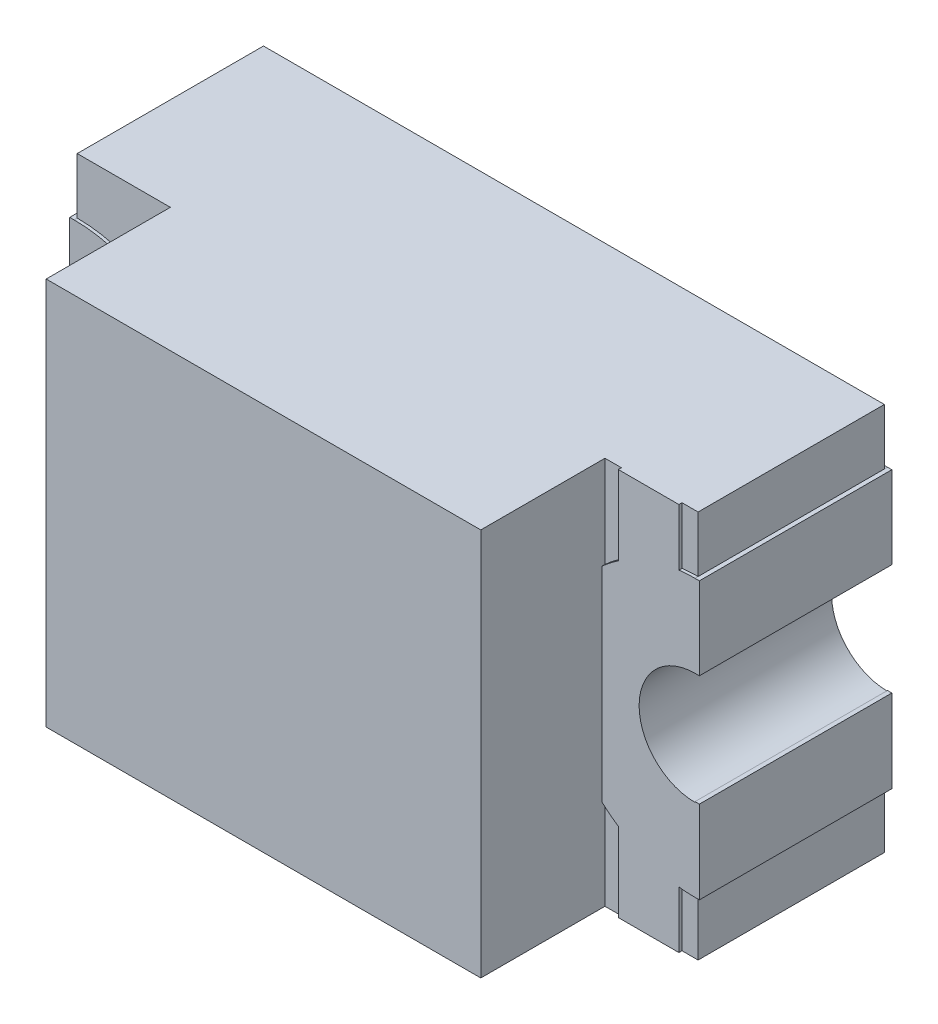
from build123d import *

# Parameters (mm, degrees)
SKETCH1_W           = 2
SKETCH1_H           = 1.25
BOSS_EXTRUDE1_DEPTH = 0.6
SKETCH2_W           = 1.4
SKETCH2_H           = 1.25
BOSS_EXTRUDE2_DEPTH = 1
BOSS_EXTRUDE3_START = -0.01
BOSS_EXTRUDE3_DEPTH = 0.62
SKETCH4_W           = 0.19540743
SKETCH4_H           = 1.25
BOSS_EXTRUDE4_DEPTH = 0.61
SKETCH7_W           = 0.413440983
SKETCH7_H           = 1.07
BOSS_EXTRUDE5_DEPTH = 0.01
SKETCH8_R           = 0.18
CUT_EXTRUDE1_DEPTH  = 3.561737691
BOSS_EXTRUDE6_START = -0.01
SKETCH9_W           = 0.014061716
SKETCH9_H           = 0.265
SKETCH9_H_2         = 0.267076393
BOSS_EXTRUDE6_DEPTH = 0.62


with BuildPart() as part:
    # Sketch1 → Boss-Extrude1 (new body)
    with BuildSketch(Plane.XY):
        with Locations((1, 0.625)):
            Rectangle(SKETCH1_W, SKETCH1_H)
    extrude(amount=BOSS_EXTRUDE1_DEPTH)

    # Sketch2 → Boss-Extrude2 (add)
    with BuildSketch(Plane.XY):
        with Locations((1, 0.625)):
            Rectangle(SKETCH2_W, SKETCH2_H)
    extrude(amount=BOSS_EXTRUDE2_DEPTH)

    # Sketch3 → Boss-Extrude3 (add)
    with BuildSketch(Plane.XY.offset(BOSS_EXTRUDE3_START)):
        with BuildLine():
            ThreePointArc((0.445, 0.625), (0.314662518, 0.939662518), (0, 1.07))
            Line((0, 1.07), (0, 0.18))
            ThreePointArc((0, 0.18), (0.314662518, 0.310337482), (0.445, 0.625))
        make_face()
    boss_extrude3 = extrude(amount=BOSS_EXTRUDE3_DEPTH)

    # Mirror1: Boss-Extrude3 across plane
    add(boss_extrude3.mirror(Plane(origin=(1, 0, 0), x_dir=(0, 0, 1), z_dir=(1, 0, 0))))

    # Sketch4 → Boss-Extrude4 (add)
    with BuildSketch(Plane.XY):
        with Locations((1.850536551, 0.625)):
            Rectangle(SKETCH4_W, SKETCH4_H)
    extrude(amount=BOSS_EXTRUDE4_DEPTH)

    # Sketch7 → Boss-Extrude5 (add)
    with BuildSketch(Plane.XY):
        with Locations((1.764145898, 0.625)):
            Rectangle(SKETCH7_W, SKETCH7_H)
    boss_extrude5 = extrude(amount=-BOSS_EXTRUDE5_DEPTH)

    # Mirror2: Boss-Extrude5 across plane
    add(boss_extrude5.mirror(Plane(origin=(1, 0, 0), x_dir=(0, 0, 1), z_dir=(1, 0, 0))))

    # Sketch8 → Cut-Extrude1 (cut, symmetric)
    with BuildSketch(Plane.XY):
        with Locations((0, 0.625)):
            Circle(SKETCH8_R)
    cut_extrude1 = extrude(amount=CUT_EXTRUDE1_DEPTH, both=True, mode=Mode.SUBTRACT)

    # Mirror3: Cut-Extrude1 across plane
    add(cut_extrude1.mirror(Plane(origin=(1, 0, 0), x_dir=(0, 0, 1), z_dir=(1, 0, 0))), mode=Mode.SUBTRACT)

    # Sketch9 → Boss-Extrude6 (add)
    with BuildSketch(Plane.XY.offset(BOSS_EXTRUDE6_START)):
        with Locations((-0.007030858, 0.9375)):
            Rectangle(SKETCH9_W, SKETCH9_H)
        with Locations((-0.007030858, 0.313538197)):
            Rectangle(SKETCH9_W, SKETCH9_H_2)
    boss_extrude6 = extrude(amount=BOSS_EXTRUDE6_DEPTH)

    # Mirror4: Boss-Extrude6 across plane
    add(boss_extrude6.mirror(Plane(origin=(1, 0, 0), x_dir=(0, 0, 1), z_dir=(1, 0, 0))))


solid = part.part
